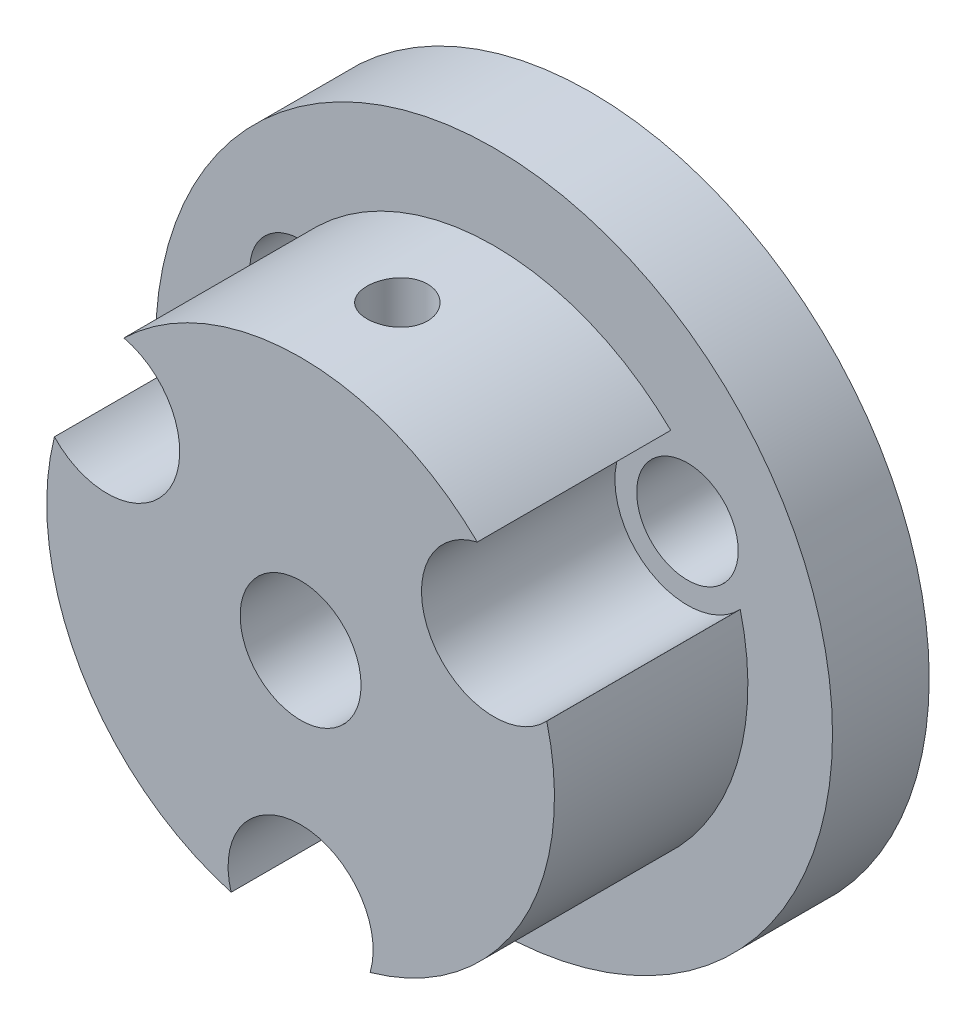
from build123d import *

# Parameters (mm, degrees)
SKIZZE1_R                       = 14
AUFSATZ_LINEAR_AUSTRAGEN1_DEPTH = 4
SKIZZE3_R                       = 2.1
SCHNITT_LINEAR_AUSTRAGEN1_DEPTH = 5
SKIZZE2_R                       = 10.5
AUFSATZ_LINEAR_AUSTRAGEN2_DEPTH = 8
SCHNITT_LINEAR_AUSTRAGEN2_REACH = 10
SKIZZE5_R                       = 3
SKIZZE6_R                       = 2.5
SCHNITT_LINEAR_AUSTRAGEN3_DEPTH = 13
SCHNITT_LINEAR_AUSTRAGEN4_REACH = 26.5
SKIZZE7_R                       = 1.25


with BuildPart() as part:
    # Skizze1 → Aufsatz-Linear austragen1 (new body)
    with BuildSketch(Plane.XY):
        Circle(SKIZZE1_R)
    extrude(amount=AUFSATZ_LINEAR_AUSTRAGEN1_DEPTH)

    # Skizze3 → Schnitt-Linear austragen1 (cut, through all)
    with BuildSketch(Plane.XY.offset(4)):
        with Locations((-8, 4.618802154)):
            Circle(SKIZZE3_R)
        with Locations((8, 4.618802154)):
            Circle(SKIZZE3_R)
        with Locations((0, -9.237604307)):
            Circle(SKIZZE3_R)
    extrude(amount=-SCHNITT_LINEAR_AUSTRAGEN1_DEPTH, mode=Mode.SUBTRACT)

    # Skizze2 → Aufsatz-Linear austragen2 (add)
    with BuildSketch(Plane.XY.offset(4)):
        Circle(SKIZZE2_R)
    extrude(amount=AUFSATZ_LINEAR_AUSTRAGEN2_DEPTH)

    # Skizze5 → Schnitt-Linear austragen2 (cut, up to next)
    with BuildSketch(Plane(origin=(0, 0, 4), x_dir=(-1, 0, 0), z_dir=(0, 0, -1)), mode=Mode.PRIVATE) as schnitt_linear_austragen2_sk1:
        with Locations((-8, 4.618802154)):
            Circle(SKIZZE5_R)
    schnitt_linear_austragen2_tool1 = extrude(schnitt_linear_austragen2_sk1.sketch, amount=-SCHNITT_LINEAR_AUSTRAGEN2_REACH, mode=Mode.PRIVATE) & part.part
    add(schnitt_linear_austragen2_tool1.solids().sort_by_distance((8, 4.618802, 4))[0], mode=Mode.SUBTRACT)
    # Skizze5 → Schnitt-Linear austragen2 (cut, up to next)
    with BuildSketch(Plane(origin=(0, 0, 4), x_dir=(-1, 0, 0), z_dir=(0, 0, -1)), mode=Mode.PRIVATE) as schnitt_linear_austragen2_sk2:
        with Locations((8, 4.618802154)):
            Circle(SKIZZE5_R)
    schnitt_linear_austragen2_tool2 = extrude(schnitt_linear_austragen2_sk2.sketch, amount=-SCHNITT_LINEAR_AUSTRAGEN2_REACH, mode=Mode.PRIVATE) & part.part
    add(schnitt_linear_austragen2_tool2.solids().sort_by_distance((-8, 4.618802, 4))[0], mode=Mode.SUBTRACT)
    # Skizze5 → Schnitt-Linear austragen2 (cut, up to next)
    with BuildSketch(Plane(origin=(0, 0, 4), x_dir=(-1, 0, 0), z_dir=(0, 0, -1)), mode=Mode.PRIVATE) as schnitt_linear_austragen2_sk3:
        with Locations((0, -9.237604307)):
            Circle(SKIZZE5_R)
    schnitt_linear_austragen2_tool3 = extrude(schnitt_linear_austragen2_sk3.sketch, amount=-SCHNITT_LINEAR_AUSTRAGEN2_REACH, mode=Mode.PRIVATE) & part.part
    add(schnitt_linear_austragen2_tool3.solids().sort_by_distance((0, -9.237604, 4))[0], mode=Mode.SUBTRACT)

    # Skizze6 → Schnitt-Linear austragen3 (cut, through all)
    with BuildSketch(Plane.XY.offset(12)):
        Circle(SKIZZE6_R)
    extrude(amount=-SCHNITT_LINEAR_AUSTRAGEN3_DEPTH, mode=Mode.SUBTRACT)

    # Skizze7 → Schnitt-Linear austragen4 (cut, up to next)
    with BuildSketch(Plane(origin=(0, 10.5, 0), x_dir=(1, 0, 0), z_dir=(0, 1, 0)), mode=Mode.PRIVATE) as schnitt_linear_austragen4_sk1:
        with Locations((0, -8)):
            Circle(SKIZZE7_R)
    schnitt_linear_austragen4_tool1 = extrude(schnitt_linear_austragen4_sk1.sketch, amount=-SCHNITT_LINEAR_AUSTRAGEN4_REACH, mode=Mode.PRIVATE) & part.part
    add(schnitt_linear_austragen4_tool1.solids().sort_by_distance((0, 10.5, 8))[0], mode=Mode.SUBTRACT)


solid = part.part
